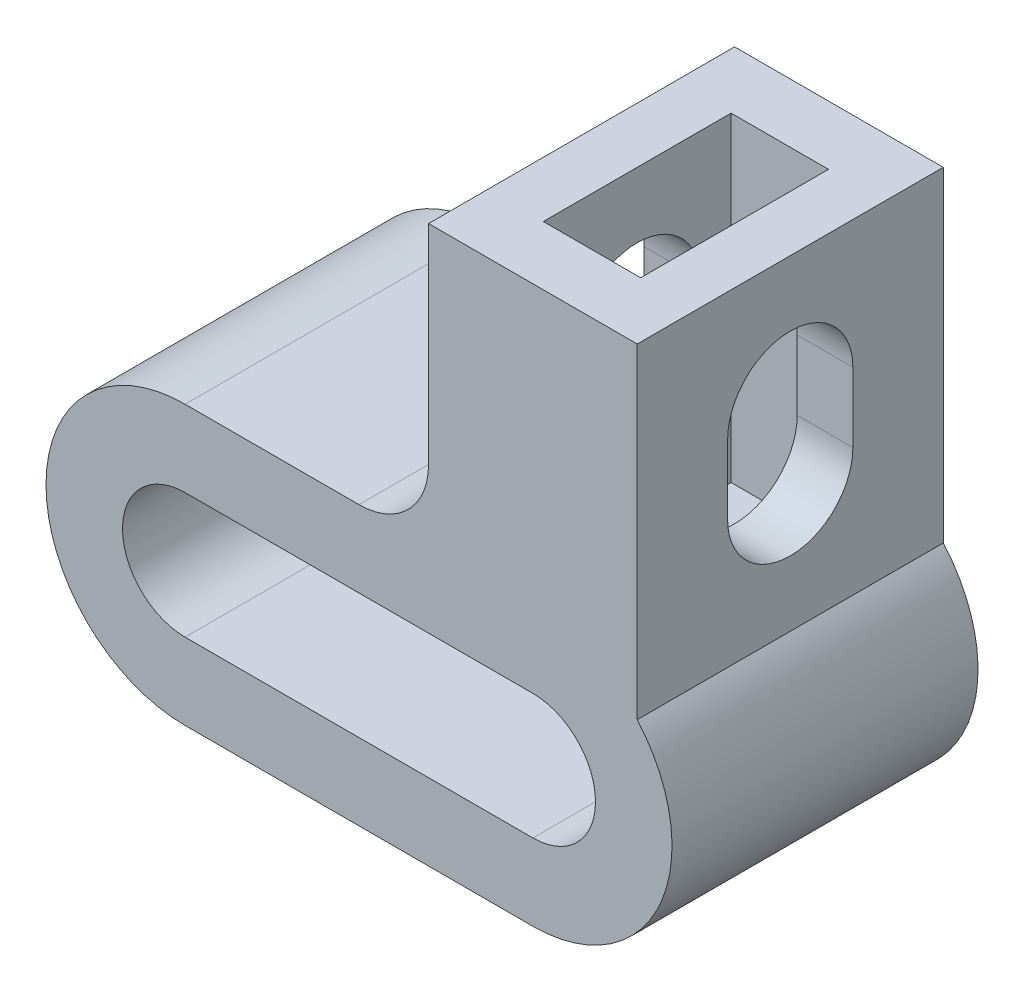
from build123d import *

# Parameters (mm, degrees)
RESSALTO_EXTRUS_O1_DEPTH   = 22
ESBO_O2_W                  = 7
ESBO_O2_H                  = 13.5
CORTE_EXTRUS_O1_DEPTH      = 23
CORTE_EXTRUS_O2_DEPTH      = 10
CORTE_EXTRUS_O2_DEPTH_BACK = 35


with BuildPart() as part:
    # Esboço1 → Ressalto-extrusão1 (new body)
    with BuildSketch(Plane.XY):
        with BuildLine():
            Line((7.5, 6.614378278), (7.5, 30))
            Line((7.5, 30), (-7.5, 30))
            Line((-7.5, 30), (-7.5, 15))
            ThreePointArc((-7.5, 15), (-8.964466094, 11.464466094), (-12.5, 10))
            Line((-12.5, 10), (-25, 10))
            ThreePointArc((-25, 10), (-35, 0), (-25, -10))
            Line((-25, -10), (0, -10))
            ThreePointArc((0, -10), (9.114378278, -4.114378278), (7.5, 6.614378278))
        make_face()
        with BuildLine():
            Line((-25, 4.5), (0, 4.5))
            ThreePointArc((0, 4.5), (4.5, 0), (0, -4.5))
            Line((0, -4.5), (-25, -4.5))
            ThreePointArc((-25, -4.5), (-29.5, 0), (-25, 4.5))
        make_face(mode=Mode.SUBTRACT)
    extrude(amount=RESSALTO_EXTRUS_O1_DEPTH)

    # Esboço2 → Corte-extrusão1 (cut)
    with BuildSketch(Plane(origin=(0, 30, 0), x_dir=(1, 0, 0), z_dir=(0, 1, 0))):
        with Locations((0, -11)):
            Rectangle(ESBO_O2_W, ESBO_O2_H)
    extrude(amount=-CORTE_EXTRUS_O1_DEPTH, mode=Mode.SUBTRACT)

    # Esboço3 → Corte-extrusão2 (cut, two sides)
    with BuildSketch(Plane(origin=(7.5, 0, 0), x_dir=(0, 0, -1), z_dir=(1, 0, 0))) as corte_extrus_o2_sk:
        with BuildLine():
            Line((-15.5, 15.807189139), (-15.5, 20.807189139))
            ThreePointArc((-15.5, 20.807189139), (-11, 25.307189139), (-6.5, 20.807189139))
            Line((-6.5, 20.807189139), (-6.5, 15.807189139))
            ThreePointArc((-6.5, 15.807189139), (-11, 11.307189139), (-15.5, 15.807189139))
        make_face()
    extrude(amount=CORTE_EXTRUS_O2_DEPTH, mode=Mode.SUBTRACT)
    extrude(corte_extrus_o2_sk.sketch, amount=-CORTE_EXTRUS_O2_DEPTH_BACK, mode=Mode.SUBTRACT)


solid = part.part
